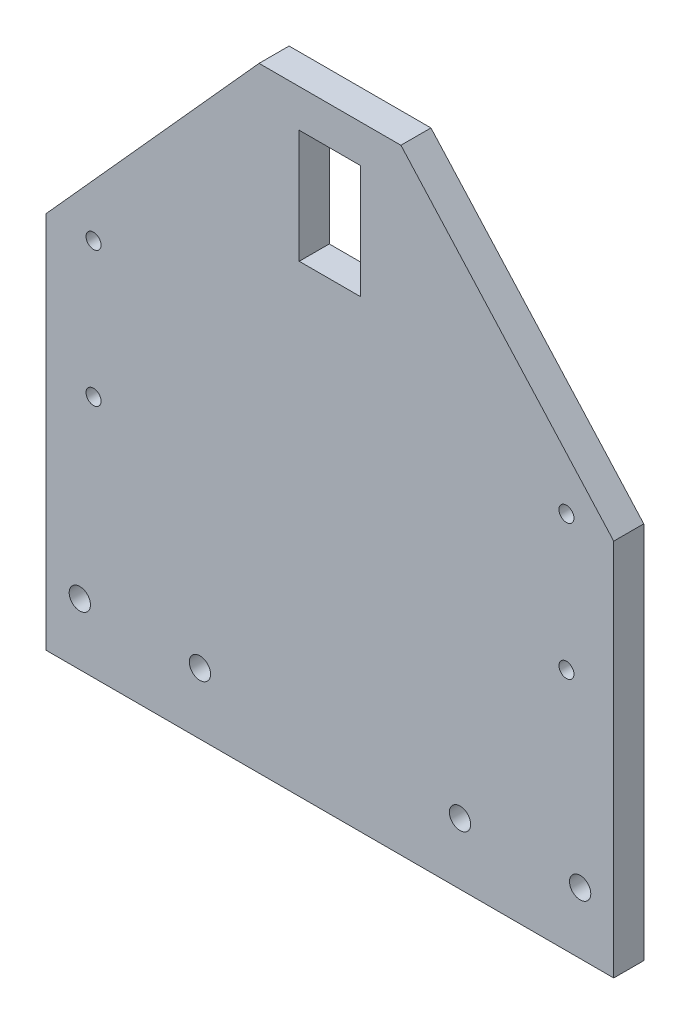
from build123d import *

# Parameters (mm, degrees)
BOSS_EXTRUDE1_DEPTH = 3.175
SKETCH3_R           = 2.25
SKETCH3_R_2         = 1.5875
SKETCH3_W           = 13
SKETCH3_H           = 24
CUT_EXTRUDE1_DEPTH  = 7.35


with BuildPart() as part:
    # Sketch1 → Boss-Extrude1 (new body, symmetric)
    with BuildSketch(Plane.XY):
        Polygon((60, 0), (-60, 0), (-60, 80), (-15, 130), (15, 130), (60, 80), align=None)
    extrude(amount=BOSS_EXTRUDE1_DEPTH, both=True)

    # Sketch3 → Cut-Extrude1 (cut, through all)
    with BuildSketch(Plane.XY.offset(3.175)):
        with Locations((-52.9, 13)):
            Circle(SKETCH3_R)
        with Locations((-27.5, 13)):
            Circle(SKETCH3_R)
        with Locations((27.5, 13)):
            Circle(SKETCH3_R)
        with Locations((52.9, 13)):
            Circle(SKETCH3_R)
        with Locations((-50, 80)):
            Circle(SKETCH3_R_2)
        with Locations((-50, 51.425)):
            Circle(SKETCH3_R_2)
        with Locations((50, 51.425)):
            Circle(SKETCH3_R_2)
        with Locations((50, 80)):
            Circle(SKETCH3_R_2)
        with Locations((0, 110)):
            Rectangle(SKETCH3_W, SKETCH3_H)
    extrude(amount=-CUT_EXTRUDE1_DEPTH, mode=Mode.SUBTRACT)


solid = part.part
